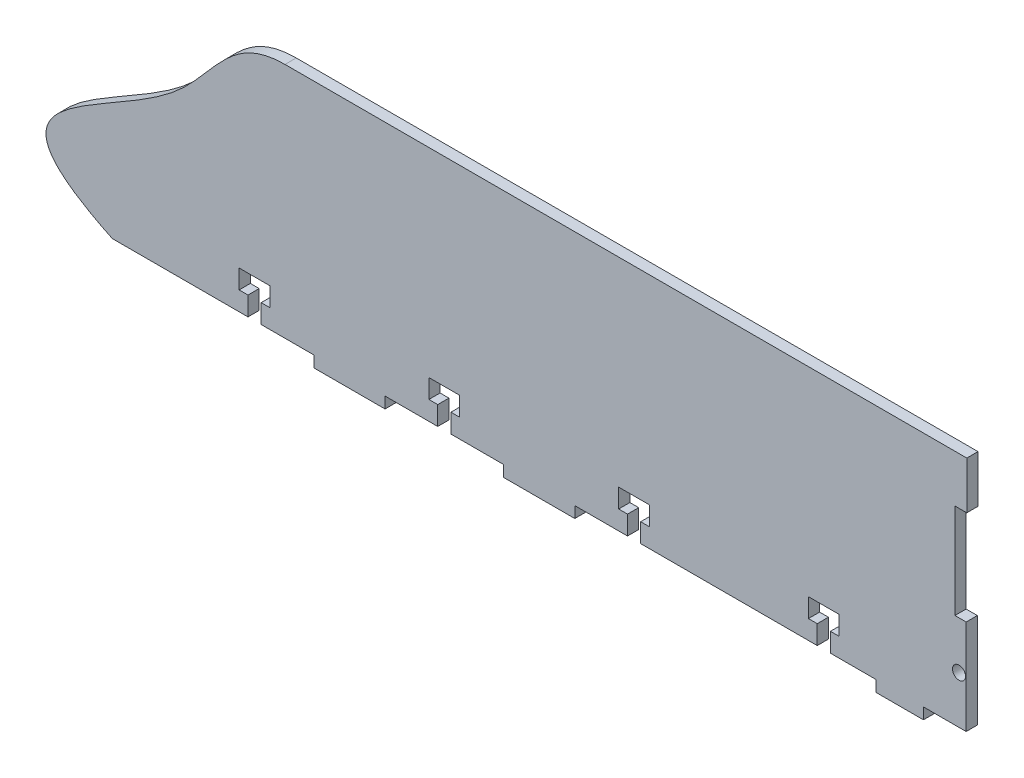
from build123d import *

# Parameters (mm, degrees)
SKETCH1_R           = 1.7526
BOSS_EXTRUDE1_DEPTH = 3


with BuildPart() as part:
    # Sketch1 → Boss-Extrude1 (new body)
    with BuildSketch(Plane.XY):
        with BuildLine():
            Line((-68.050090825, 31.75), (111.125, 31.75))
            Line((111.125, 31.75), (114.475, 31.75))
            Line((114.475, 31.75), (114.475, 19.05))
            Line((114.475, 19.05), (111.3, 19.05))
            Line((111.3, 19.05), (111.3, -6.35))
            Line((111.3, -6.35), (114.3, -6.35))
            Line((114.3, -6.35), (114.3, -18.229405084))
            Line((114.3, -18.229405084), (114.3, -19.870594916))
            Line((114.3, -19.870594916), (114.3, -31.75))
            Line((114.3, -31.75), (111.125, -31.75))
            Line((111.125, -31.75), (102.87, -31.75))
            Line((102.87, -31.75), (102.87, -34.75))
            Line((102.87, -34.75), (90.17, -34.75))
            Line((90.17, -34.75), (90.17, -31.75))
            Line((90.17, -31.75), (88.19515, -31.75))
            Line((88.19515, -31.75), (77.9653, -31.75))
            Line((77.9653, -31.75), (77.9653, -26.67))
            Line((77.9653, -26.67), (80.3275, -26.67))
            Line((80.3275, -26.67), (80.3275, -21.59))
            Line((80.3275, -21.59), (72.0725, -21.59))
            Line((72.0725, -21.59), (72.0725, -26.67))
            Line((72.0725, -26.67), (74.4347, -26.67))
            Line((74.4347, -26.67), (74.4347, -31.75))
            Line((74.4347, -31.75), (27.1653, -31.75))
            Line((27.1653, -31.75), (27.1653, -26.67))
            Line((27.1653, -26.67), (29.5275, -26.67))
            Line((29.5275, -26.67), (29.5275, -21.59))
            Line((29.5275, -21.59), (21.2725, -21.59))
            Line((21.2725, -21.59), (21.2725, -26.67))
            Line((21.2725, -26.67), (23.6347, -26.67))
            Line((23.6347, -26.67), (23.6347, -31.75))
            Line((23.6347, -31.75), (9.525, -31.75))
            Line((9.525, -31.75), (9.525, -34.75))
            Line((9.525, -34.75), (-9.525, -34.75))
            Line((-9.525, -34.75), (-9.525, -31.75))
            Line((-9.525, -31.75), (-23.6347, -31.75))
            Line((-23.6347, -31.75), (-23.6347, -26.67))
            Line((-23.6347, -26.67), (-21.2725, -26.67))
            Line((-21.2725, -26.67), (-21.2725, -21.59))
            Line((-21.2725, -21.59), (-29.5275, -21.59))
            Line((-29.5275, -21.59), (-29.5275, -26.67))
            Line((-29.5275, -26.67), (-27.1653, -26.67))
            Line((-27.1653, -26.67), (-27.1653, -31.75))
            Line((-27.1653, -31.75), (-41.275, -31.75))
            Line((-41.275, -31.75), (-41.275, -34.75))
            Line((-41.275, -34.75), (-60.325, -34.75))
            Line((-60.325, -34.75), (-60.325, -31.75))
            Line((-60.325, -31.75), (-74.4347, -31.75))
            Line((-74.4347, -31.75), (-74.4347, -26.67))
            Line((-74.4347, -26.67), (-72.0725, -26.67))
            Line((-72.0725, -26.67), (-72.0725, -21.59))
            Line((-72.0725, -21.59), (-80.3275, -21.59))
            Line((-80.3275, -21.59), (-80.3275, -26.67))
            Line((-80.3275, -26.67), (-77.9653, -26.67))
            Line((-77.9653, -26.67), (-77.9653, -31.75))
            Line((-77.9653, -31.75), (-114.3, -31.75))
            add(Edge.make_bspline(
                [(-114.3, -31.75), (-155.042938789, -12.240400658), (-94.548851624, -1.377525337), (-82.535055103, 31.754341042), (-68.050090825, 31.75)],
                knots=[0, 0, 0, 0, 0.655069171, 1, 1, 1, 1], degree=3))
        make_face()
        with Locations((112.395, -19.05)):
            Circle(SKETCH1_R, mode=Mode.SUBTRACT)
    extrude(amount=BOSS_EXTRUDE1_DEPTH)


solid = part.part
